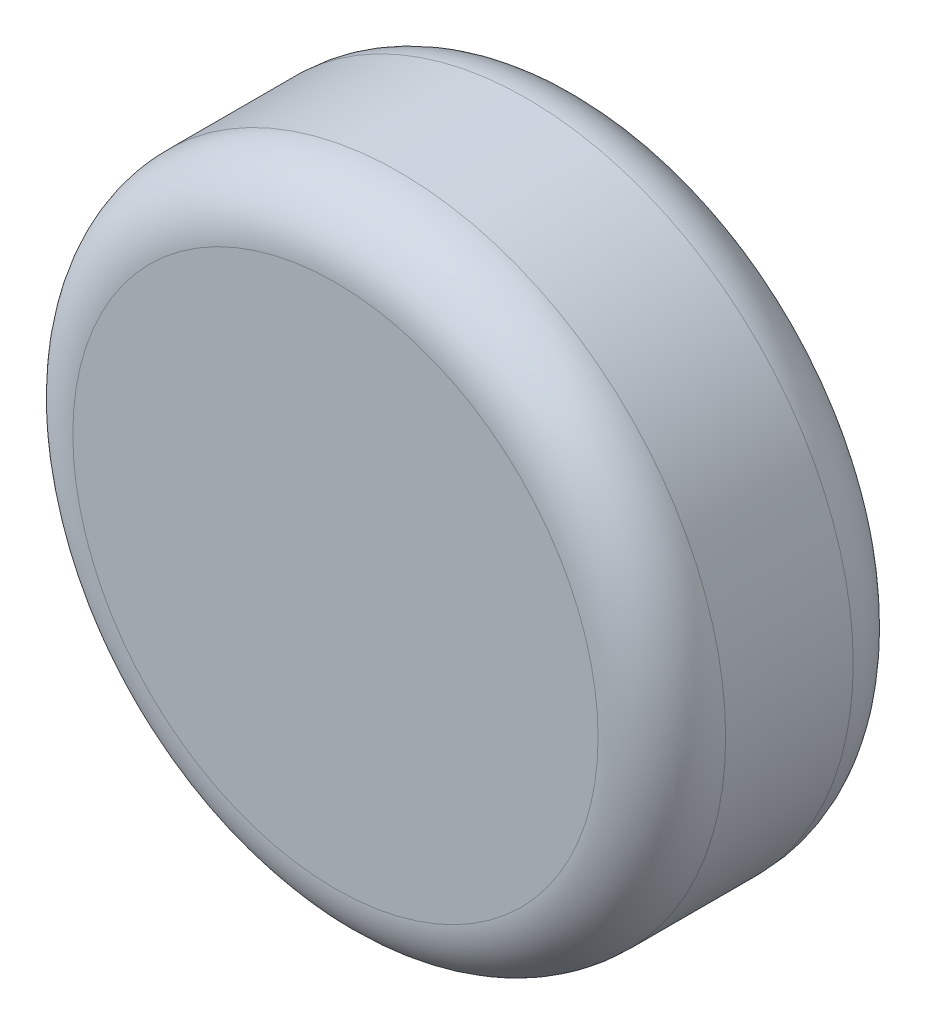
from build123d import *

# Parameters (mm, degrees)
SKETCH1_R           = 32.5
BOSS_EXTRUDE1_DEPTH = 25.4
FILLET1_R           = 6.35
CUT_EXTRUDE1_DEPTH  = 15.621


with BuildPart() as part:
    # Sketch1 → Boss-Extrude1 (new body)
    with BuildSketch(Plane.XY):
        Circle(SKETCH1_R)
    extrude(amount=BOSS_EXTRUDE1_DEPTH)

    # Fillet1
    fillet1_edges = [part.edges().sort_by_distance(p)[0] for p in [
        (-32.5, 0, 0),
        (-32.5, 0, 25.4),
    ]]
    fillet(fillet1_edges, radius=FILLET1_R)

    # Sketch2 → Cut-Extrude1 (cut)
    with BuildSketch(Plane(origin=(0, 0, 0), x_dir=(-1, 0, 0), z_dir=(0, 0, -1))):
        Polygon((3.464101615, -6), (6.92820323, 0), (3.464101615, 6), (-3.464101615, 6), (-6.92820323, 0), (-3.464101615, -6), align=None)
    extrude(amount=-CUT_EXTRUDE1_DEPTH, mode=Mode.SUBTRACT)


solid = part.part
